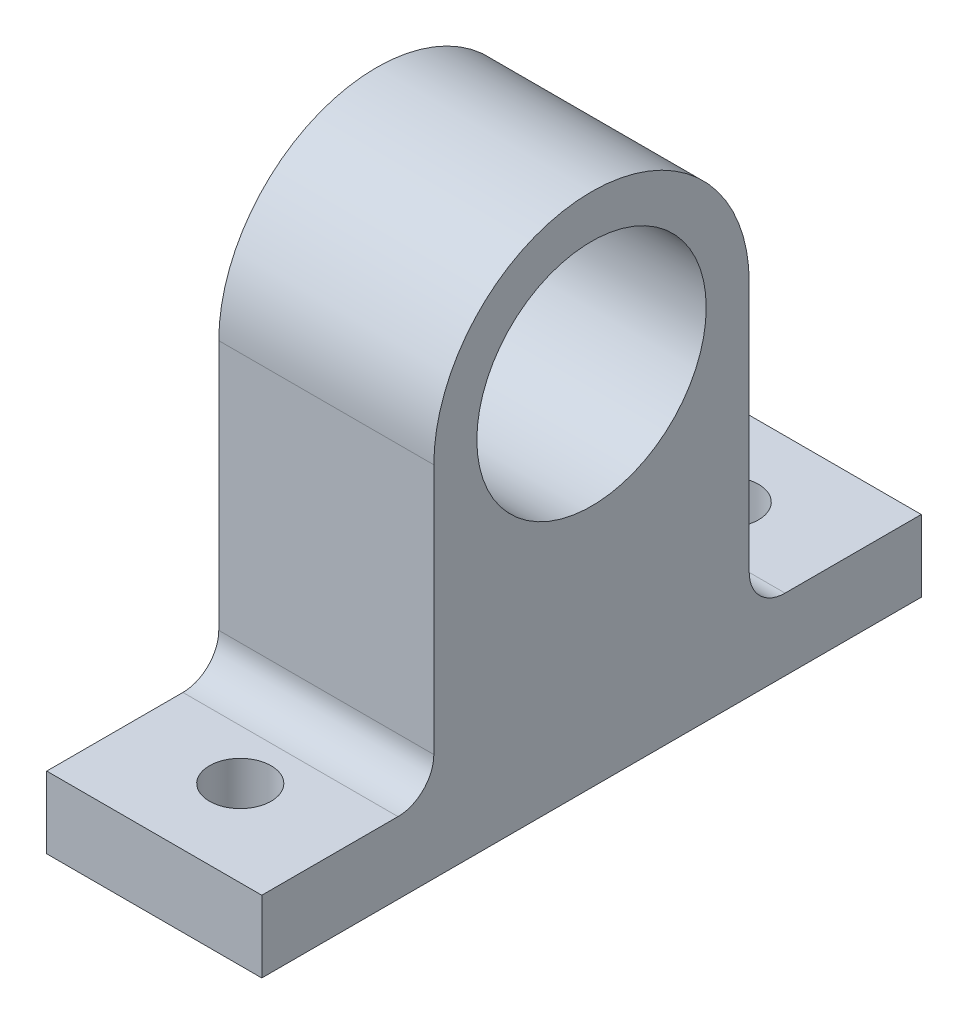
from build123d import *

# Parameters (mm, degrees)
SKETCH1_R                = 8
BOSS_EXTRUDE1_DEPTH      = 15
SKETCH2_W                = 15
SKETCH2_H                = 5
BOSS_EXTRUDE2_DEPTH      = 12
BOSS_EXTRUDE2_DEPTH_BACK = 34
SKETCH3_R                = 2.15
CUT_EXTRUDE1_DEPTH       = 5
FILLET1_R                = 2.5


with BuildPart() as part:
    # Sketch1 → Boss-Extrude1 (new body)
    with BuildSketch(Plane(origin=(0, 0, 0), x_dir=(0, 0, -1), z_dir=(1, 0, 0))):
        with BuildLine():
            Line((-11, 12.5), (-11, -12.5))
            Line((-11, -12.5), (11, -12.5))
            Line((11, -12.5), (11, 12.5))
            ThreePointArc((11, 12.5), (0, 23.5), (-11, 12.5))
        make_face()
        with Locations((0, 12.5)):
            Circle(SKETCH1_R, mode=Mode.SUBTRACT)
    extrude(amount=BOSS_EXTRUDE1_DEPTH)

    # Sketch2 → Boss-Extrude2 (add, two sides)
    with BuildSketch(Plane.XY.offset(11)) as boss_extrude2_sk:
        with Locations((7.5, -10)):
            Rectangle(SKETCH2_W, SKETCH2_H)
    extrude(amount=BOSS_EXTRUDE2_DEPTH)
    extrude(boss_extrude2_sk.sketch, amount=-BOSS_EXTRUDE2_DEPTH_BACK)

    # Sketch3 → Cut-Extrude1 (cut)
    with BuildSketch(Plane(origin=(0, -7.5, 0), x_dir=(1, 0, 0), z_dir=(0, 1, 0))):
        with Locations((7.5, -17)):
            Circle(SKETCH3_R)
        with Locations((7.5, 17)):
            Circle(SKETCH3_R)
    extrude(amount=-CUT_EXTRUDE1_DEPTH, mode=Mode.SUBTRACT)

    # Fillet1
    fillet1_edges = [part.edges().sort_by_distance(p)[0] for p in [
        (7.5, -7.5, 11),
        (7.5, -7.5, -11),
    ]]
    fillet(fillet1_edges, radius=FILLET1_R)


solid = part.part
